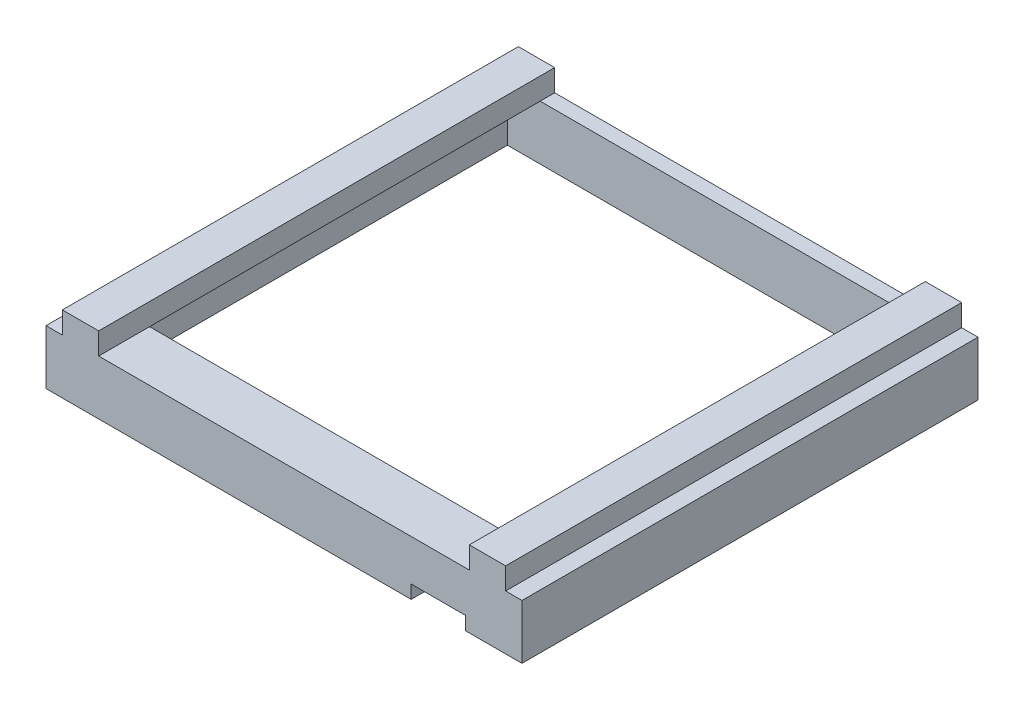
from build123d import *

# Parameters (mm, degrees)
BOSS_EXTRUDE1_DEPTH  = 15
SKETCH8_W            = 10
SKETCH8_H            = 5.5
BOSS_EXTRUDE2_DEPTH  = 6
BOSS_EXTRUDE3_DEPTH  = 120
SKETCH10_W           = 8
SKETCH10_H           = 5.5
BOSS_EXTRUDE4_DEPTH  = 5
SKETCH11_W           = 5.5
SKETCH11_H           = 11.334625819
BOSS_EXTRUDE5_DEPTH  = 15
SKETCH12_W           = 10
SKETCH12_H           = 5.5
BOSS_EXTRUDE6_DEPTH  = 6
BOSS_EXTRUDE7_DEPTH  = 120
SKETCH14_W           = 9
SKETCH14_H           = 5.5
BOSS_EXTRUDE8_DEPTH  = 6
SKETCH15_W           = 104
SKETCH15_H           = 3
BOSS_EXTRUDE11_DEPTH = 8.5
CUT_EXTRUDE1_DEPTH   = 1.5


with BuildPart() as part:
    # Sketch2 → Boss-Extrude1 (new body)
    with BuildSketch(Plane(origin=(0, 0, 0), x_dir=(1, 0, 0), z_dir=(0, 1, 0))):
        Polygon((-98.263888889, -54.75), (-98.263888889, 59.75), (21.736111111, 59.75), (21.736111111, -54.75), (11.736111111, -54.75), (11.736111111, -60.25), (27.236111111, -60.25), (27.236111111, 65.25), (-103.763888889, 65.25), (-103.763888889, -60.25), (-3.263888889, -60.25), (-3.263888889, -54.75), align=None)
    extrude(amount=BOSS_EXTRUDE1_DEPTH)

    # Sketch8 → Boss-Extrude2 (add)
    with BuildSketch(Plane(origin=(0, 15, 0), x_dir=(1, 0, 0), z_dir=(0, 1, 0))):
        with Locations((-94.263888889, -57.5)):
            Rectangle(SKETCH8_W, SKETCH8_H)
    extrude(amount=BOSS_EXTRUDE2_DEPTH)

    # Sketch9 → Boss-Extrude3 (add)
    with BuildSketch(Plane(origin=(0, 0, 54.75), x_dir=(-1, 0, 0), z_dir=(0, 0, -1))):
        Polygon((90.263888889, 15), (90.263888889, 16), (90.263888889, 20), (98.263888889, 20), (98.263888889, 16), (98.263888889, 15), (99.263888889, 15), (99.263888889, 21), (89.263888889, 21), (89.263888889, 15), align=None)
    extrude(amount=BOSS_EXTRUDE3_DEPTH)

    # Sketch10 → Boss-Extrude4 (add)
    with BuildSketch(Plane(origin=(0, 15, 0), x_dir=(1, 0, 0), z_dir=(0, 1, 0))):
        with Locations((-94.263888889, 62.5)):
            Rectangle(SKETCH10_W, SKETCH10_H)
    extrude(amount=BOSS_EXTRUDE4_DEPTH)

    # Sketch11 → Boss-Extrude5 (add)
    with BuildSketch(Plane(origin=(-3.263888889, 0, 0), x_dir=(0, 0, -1), z_dir=(1, 0, 0))):
        with Locations((-57.5, 9.332687091)):
            Rectangle(SKETCH11_W, SKETCH11_H)
    extrude(amount=BOSS_EXTRUDE5_DEPTH)

    # Sketch12 → Boss-Extrude6 (add)
    with BuildSketch(Plane(origin=(0, 15, 0), x_dir=(1, 0, 0), z_dir=(0, 1, 0))):
        with Locations((17.736111111, -57.5)):
            Rectangle(SKETCH12_W, SKETCH12_H)
    extrude(amount=BOSS_EXTRUDE6_DEPTH)

    # Sketch13 → Boss-Extrude7 (add)
    with BuildSketch(Plane(origin=(0, 0, 54.75), x_dir=(-1, 0, 0), z_dir=(0, 0, -1))):
        Polygon((-21.736111111, 15), (-21.736111111, 16), (-21.736111111, 20), (-13.736111111, 20), (-13.736111111, 16), (-13.736111111, 15), (-12.736111111, 15), (-12.736111111, 21), (-22.736111111, 21), (-22.736111111, 15), align=None)
    extrude(amount=BOSS_EXTRUDE7_DEPTH)

    # Sketch14 → Boss-Extrude8 (add)
    with BuildSketch(Plane(origin=(0, 15, 0), x_dir=(1, 0, 0), z_dir=(0, 1, 0))):
        with Locations((18.236111111, 62.5)):
            Rectangle(SKETCH14_W, SKETCH14_H)
    extrude(amount=BOSS_EXTRUDE8_DEPTH)

    # Sketch15 → Boss-Extrude11 (add)
    with BuildSketch(Plane(origin=(0, 0, 54.75), x_dir=(-1, 0, 0), z_dir=(0, 0, -1))):
        with Locations((38.263888889, 13.5)):
            Rectangle(SKETCH15_W, SKETCH15_H)
    extrude(amount=BOSS_EXTRUDE11_DEPTH)

    # Sketch17 → Cut-Extrude1 (cut)
    with BuildSketch(Plane.XY.offset(-59.75)):
        Polygon((-98.263888889, 0), (21.736111111, 0), (21.736111111, 20), (13.736111111, 20), (13.736111111, 15), (12.736111111, 15), (-89.263888889, 15), (-90.263888889, 15), (-90.263888889, 20), (-98.263888889, 20), align=None)
    extrude(amount=-CUT_EXTRUDE1_DEPTH, mode=Mode.SUBTRACT)


solid = part.part
